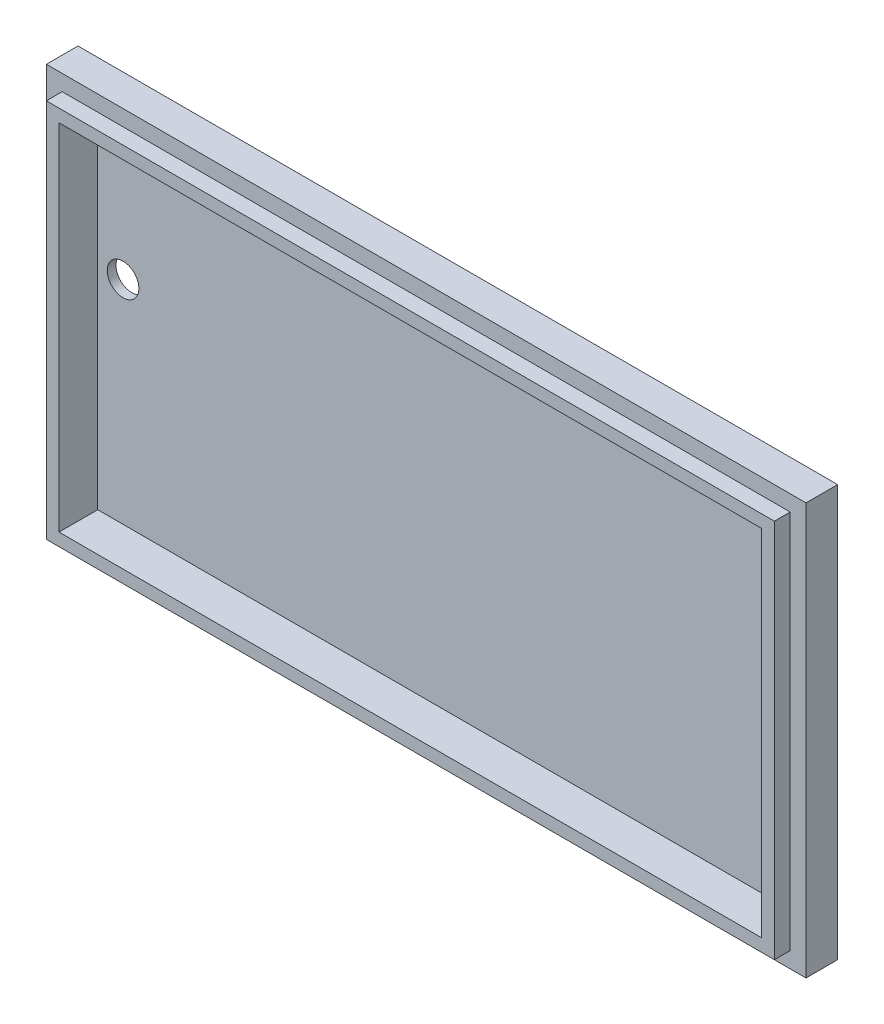
from build123d import *

# Parameters (mm, degrees)
SKETCH1_W                    = 120
SKETCH1_H                    = 65
BOSS_EXTRUDE1_DEPTH          = 5
SKETCH2_W                    = 115
SKETCH2_H                    = 60
BOSS_EXTRUDE2_DEPTH          = 2.5
F_5_0_5_DIAMETER_HOLE1_D     = 5
F_5_0_5_DIAMETER_HOLE1_DEPTH = 7.5
SKETCH5_W                    = 111
SKETCH5_H                    = 56
CUT_EXTRUDE3_DEPTH           = 6.12


with BuildPart() as part:
    # Sketch1 → Boss-Extrude1 (new body)
    with BuildSketch(Plane.XY.offset(2.5)):
        with Locations((60, 32.5)):
            Rectangle(SKETCH1_W, SKETCH1_H)
    extrude(amount=-BOSS_EXTRUDE1_DEPTH)

    # Sketch2 → Boss-Extrude2 (add)
    with BuildSketch(Plane.XY.offset(2.5)):
        with Locations((60, 32.5)):
            Rectangle(SKETCH2_W, SKETCH2_H)
    extrude(amount=BOSS_EXTRUDE2_DEPTH)

    # Ø5.0 (5) Diameter Hole1
    with Locations(Plane(origin=(0, 0, -2.5), x_dir=(-1, 0, 0), z_dir=(0, 0, -1))):
        with Locations((-8.5, 38)):
            Hole(F_5_0_5_DIAMETER_HOLE1_D / 2, depth=F_5_0_5_DIAMETER_HOLE1_DEPTH)

    # Sketch5 → Cut-Extrude3 (cut)
    with BuildSketch(Plane.XY.offset(5)):
        with Locations((60, 32.5)):
            Rectangle(SKETCH5_W, SKETCH5_H)
    extrude(amount=-CUT_EXTRUDE3_DEPTH, mode=Mode.SUBTRACT)


solid = part.part
